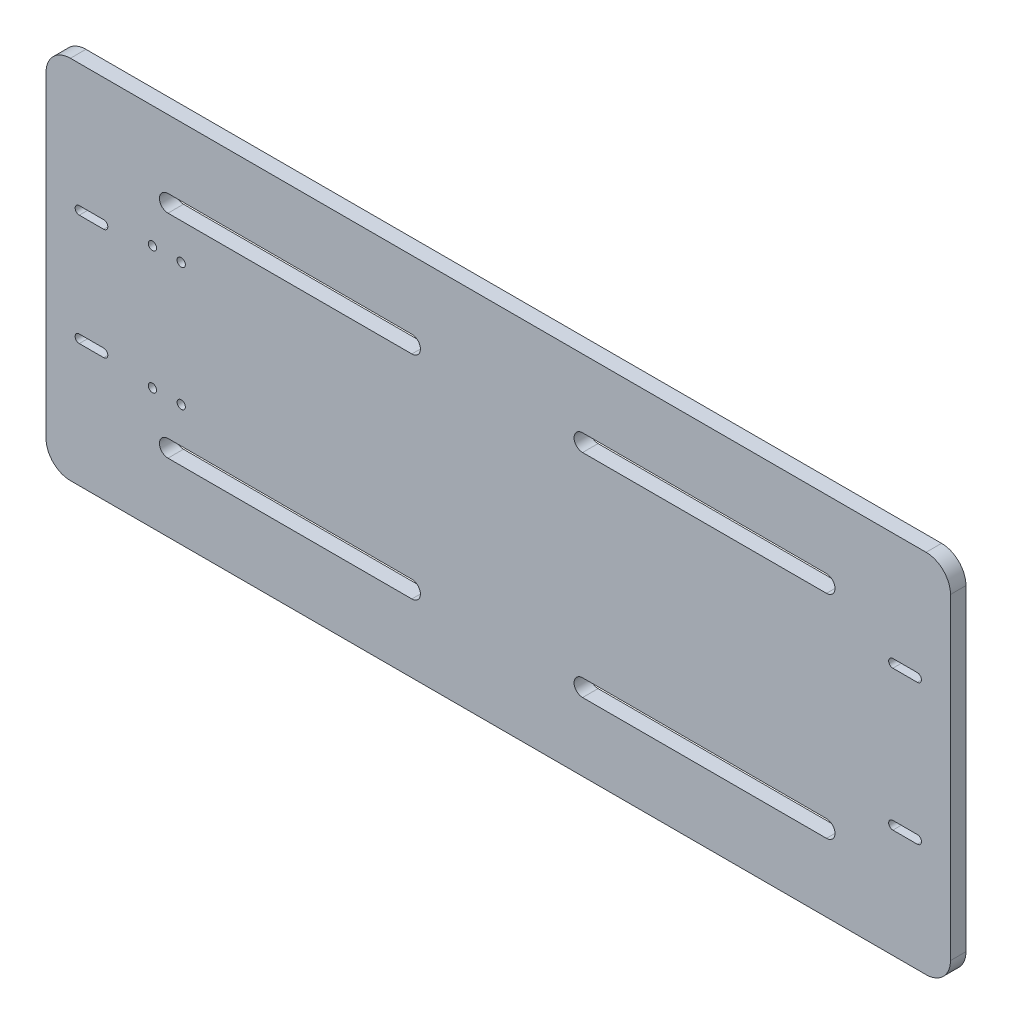
from build123d import *

# Parameters (mm, degrees)
SKETCH1_W           = 370.84
SKETCH1_H           = 150
BOSS_EXTRUDE1_DEPTH = 6.35
FILLET3_R           = 10
FILLET4_R           = 10
FILLET5_R           = 10
FILLET6_R           = 10
SKETCH3_R           = 1.7
CUT_EXTRUDE1_DEPTH  = 10
CUT_EXTRUDE2_DEPTH  = 10
SKETCH6_R           = 1.7
CUT_EXTRUDE3_DEPTH  = 7.35


with BuildPart() as part:
    # Sketch1 → Boss-Extrude1 (new body)
    with BuildSketch(Plane.XY):
        with Locations((185.42, -75)):
            Rectangle(SKETCH1_W, SKETCH1_H)
    extrude(amount=BOSS_EXTRUDE1_DEPTH)

    # Fillet3
    fillet3_edges = [part.edges().sort_by_distance(p)[0] for p in [
        (0, 0, 3.175),
    ]]
    fillet(fillet3_edges, radius=FILLET3_R)

    # Fillet4
    fillet4_edges = [part.edges().sort_by_distance(p)[0] for p in [
        (0, -150, 3.175),
    ]]
    fillet(fillet4_edges, radius=FILLET4_R)

    # Fillet5
    fillet5_edges = [part.edges().sort_by_distance(p)[0] for p in [
        (370.84, -150, 3.175),
    ]]
    fillet(fillet5_edges, radius=FILLET5_R)

    # Fillet6
    fillet6_edges = [part.edges().sort_by_distance(p)[0] for p in [
        (370.84, 0, 3.175),
    ]]
    fillet(fillet6_edges, radius=FILLET6_R)

    # Sketch3 → Cut-Extrude1 (cut)
    with BuildSketch(Plane.XY.offset(6.35)):
        with Locations((18.62, -52.205)):
            Circle(SKETCH3_R)
        with Locations((18.62, -97.795)):
            Circle(SKETCH3_R)
        with Locations((352.22, -103.75)):
            Circle(SKETCH3_R)
        with Locations((352.22, -46.25)):
            Circle(SKETCH3_R)
    extrude(amount=-CUT_EXTRUDE1_DEPTH, mode=Mode.SUBTRACT)

    # Sketch4 → Cut-Extrude2 (cut)
    with BuildSketch(Plane.XY.offset(6.35)):
        with BuildLine():
            Line((50, -28), (150, -28))
            ThreePointArc((150, -28), (153.5, -31.5), (150, -35))
            Line((150, -35), (50, -35))
            ThreePointArc((50, -35), (46.5, -31.5), (50, -28))
        make_face()
        with BuildLine():
            Line((220, -28), (320, -28))
            ThreePointArc((320, -28), (323.5, -31.5), (320, -35))
            Line((320, -35), (220, -35))
            ThreePointArc((220, -35), (216.5, -31.5), (220, -28))
        make_face()
        with BuildLine():
            Line((50, -115), (150, -115))
            ThreePointArc((150, -115), (153.5, -118.5), (150, -122))
            Line((150, -122), (50, -122))
            ThreePointArc((50, -122), (46.5, -118.5), (50, -115))
        make_face()
        with BuildLine():
            Line((220, -115), (320, -115))
            ThreePointArc((320, -115), (323.5, -118.5), (320, -122))
            Line((320, -122), (220, -122))
            ThreePointArc((220, -122), (216.5, -118.5), (220, -115))
        make_face()
    extrude(amount=-CUT_EXTRUDE2_DEPTH, mode=Mode.SUBTRACT)

    # Sketch6 → Cut-Extrude3 (cut, through all)
    with BuildSketch(Plane.XY.offset(6.35)):
        with Locations((43.62, -49.75)):
            Circle(SKETCH6_R)
        with Locations((43.62, -100.25)):
            Circle(SKETCH6_R)
        with Locations((55.42, -49.75)):
            Circle(SKETCH6_R)
        with Locations((55.42, -100.25)):
            Circle(SKETCH6_R)
        with BuildLine():
            Line((13.62, -50.505), (23.62, -50.505))
            ThreePointArc((23.62, -50.505), (25.32, -52.205), (23.62, -53.905))
            Line((23.62, -53.905), (13.62, -53.905))
            ThreePointArc((13.62, -53.905), (11.92, -52.205), (13.62, -50.505))
        make_face()
        with BuildLine():
            Line((13.62, -96.095), (23.62, -96.095))
            ThreePointArc((23.62, -96.095), (25.32, -97.795), (23.62, -99.495))
            Line((23.62, -99.495), (13.62, -99.495))
            ThreePointArc((13.62, -99.495), (11.92, -97.795), (13.62, -96.095))
        make_face()
        with BuildLine():
            Line((347.22, -44.525), (357.22, -44.525))
            ThreePointArc((357.22, -44.525), (358.945, -46.25), (357.22, -47.975))
            Line((357.22, -47.975), (347.22, -47.975))
            ThreePointArc((347.22, -47.975), (345.495, -46.25), (347.22, -44.525))
        make_face()
        with BuildLine():
            Line((347.22, -102.025), (357.22, -102.025))
            ThreePointArc((357.22, -102.025), (358.945, -103.75), (357.22, -105.475))
            Line((357.22, -105.475), (347.22, -105.475))
            ThreePointArc((347.22, -105.475), (345.495, -103.75), (347.22, -102.025))
        make_face()
    extrude(amount=-CUT_EXTRUDE3_DEPTH, mode=Mode.SUBTRACT)


solid = part.part
